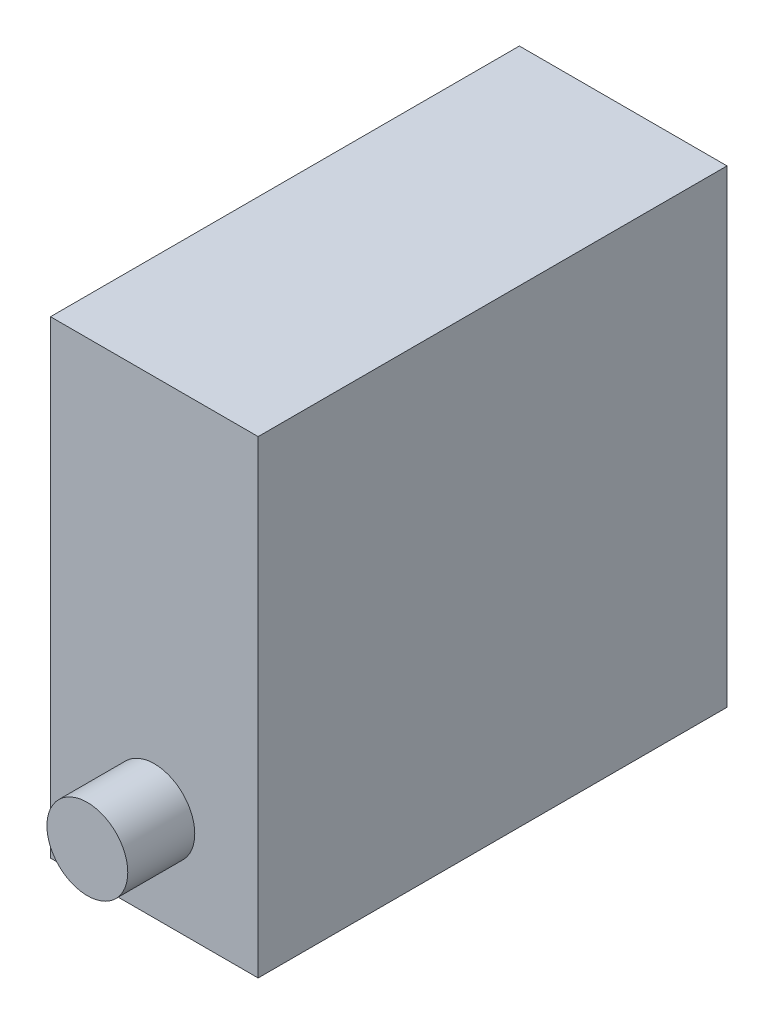
from build123d import *

# Parameters (mm, degrees)
SKETCH1_W           = 6.2
SKETCH1_H           = 14
BOSS_EXTRUDE1_DEPTH = 14
SKETCH3_R           = 1.207307889
BOSS_EXTRUDE2_DEPTH = 2


with BuildPart() as part:
    # Sketch1 → Boss-Extrude1 (new body)
    with BuildSketch(Plane.XY):
        with Locations((3.1, -7)):
            Rectangle(SKETCH1_W, SKETCH1_H)
    extrude(amount=BOSS_EXTRUDE1_DEPTH)

    # Sketch3 → Boss-Extrude2 (add)
    with BuildSketch(Plane.XY.offset(14)):
        with Locations((3.1, -11.215976381)):
            Circle(SKETCH3_R)
    extrude(amount=BOSS_EXTRUDE2_DEPTH)


solid = part.part
